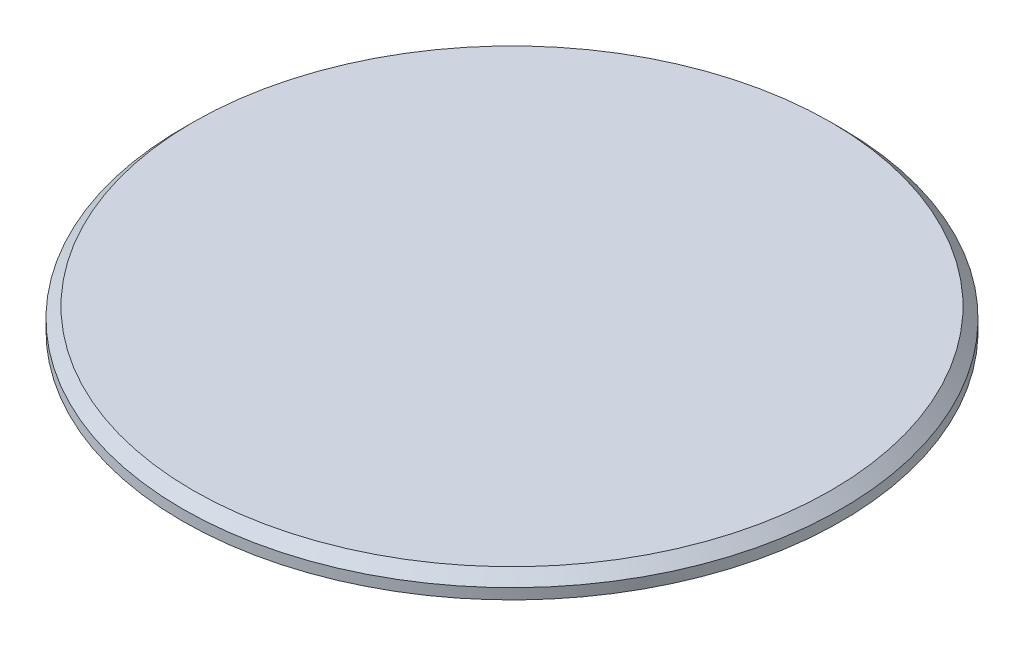
from build123d import *

# Parameters (mm, degrees)
SKETCH1_R           = 17.35
BOSS_EXTRUDE1_DEPTH = 7
SKETCH2_R           = 31
BOSS_EXTRUDE2_DEPTH = 2
SKETCH3_R           = 14.646692659
CUT_EXTRUDE1_DEPTH  = 7
CHAMFER1_SIZE       = 1


with BuildPart() as part:
    # Sketch1 → Boss-Extrude1 (new body)
    with BuildSketch(Plane(origin=(0, 0, 0), x_dir=(1, 0, 0), z_dir=(0, 1, 0))):
        Circle(SKETCH1_R)
    extrude(amount=BOSS_EXTRUDE1_DEPTH)

    # Sketch2 → Boss-Extrude2 (add)
    with BuildSketch(Plane(origin=(0, 7, 0), x_dir=(1, 0, 0), z_dir=(0, 1, 0))):
        Circle(SKETCH2_R)
    extrude(amount=BOSS_EXTRUDE2_DEPTH)

    # Sketch3 → Cut-Extrude1 (cut)
    with BuildSketch(Plane.XZ):
        Circle(SKETCH3_R)
    extrude(amount=-CUT_EXTRUDE1_DEPTH, mode=Mode.SUBTRACT)

    # Chamfer1
    chamfer1_edges = [part.edges().sort_by_distance(p)[0] for p in [
        (-31, 9, 0),
    ]]
    chamfer(chamfer1_edges, length=CHAMFER1_SIZE)


solid = part.part
